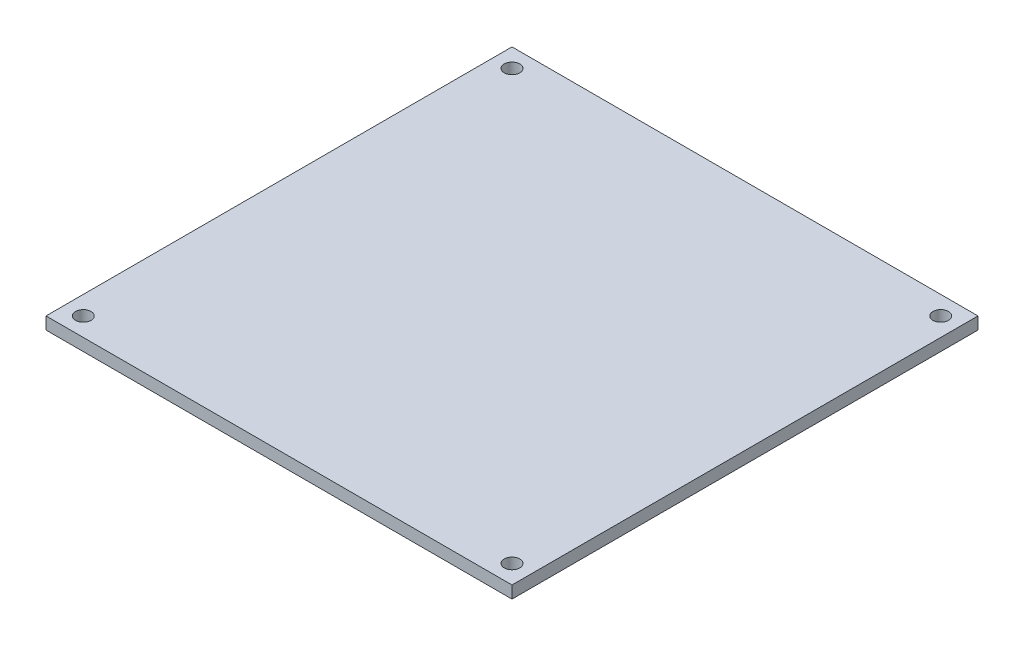
from build123d import *

# Parameters (mm, degrees)
SKETCH1_W           = 76.2
SKETCH1_H           = 76.2
SKETCH1_R           = 1.27
BOSS_EXTRUDE1_DEPTH = 2.0066


with BuildPart() as part:
    # Sketch1 → Boss-Extrude1 (new body)
    with BuildSketch(Plane(origin=(0, 0, 0), x_dir=(1, 0, 0), z_dir=(0, 1, 0))):
        Rectangle(SKETCH1_W, SKETCH1_H)
        with Locations((-35.052, 35.052)):
            Circle(SKETCH1_R, mode=Mode.SUBTRACT)
        with Locations((35.052, 35.052)):
            Circle(SKETCH1_R, mode=Mode.SUBTRACT)
        with Locations((-35.052, -35.052)):
            Circle(SKETCH1_R, mode=Mode.SUBTRACT)
        with Locations((35.052, -35.052)):
            Circle(SKETCH1_R, mode=Mode.SUBTRACT)
    extrude(amount=BOSS_EXTRUDE1_DEPTH)


solid = part.part
